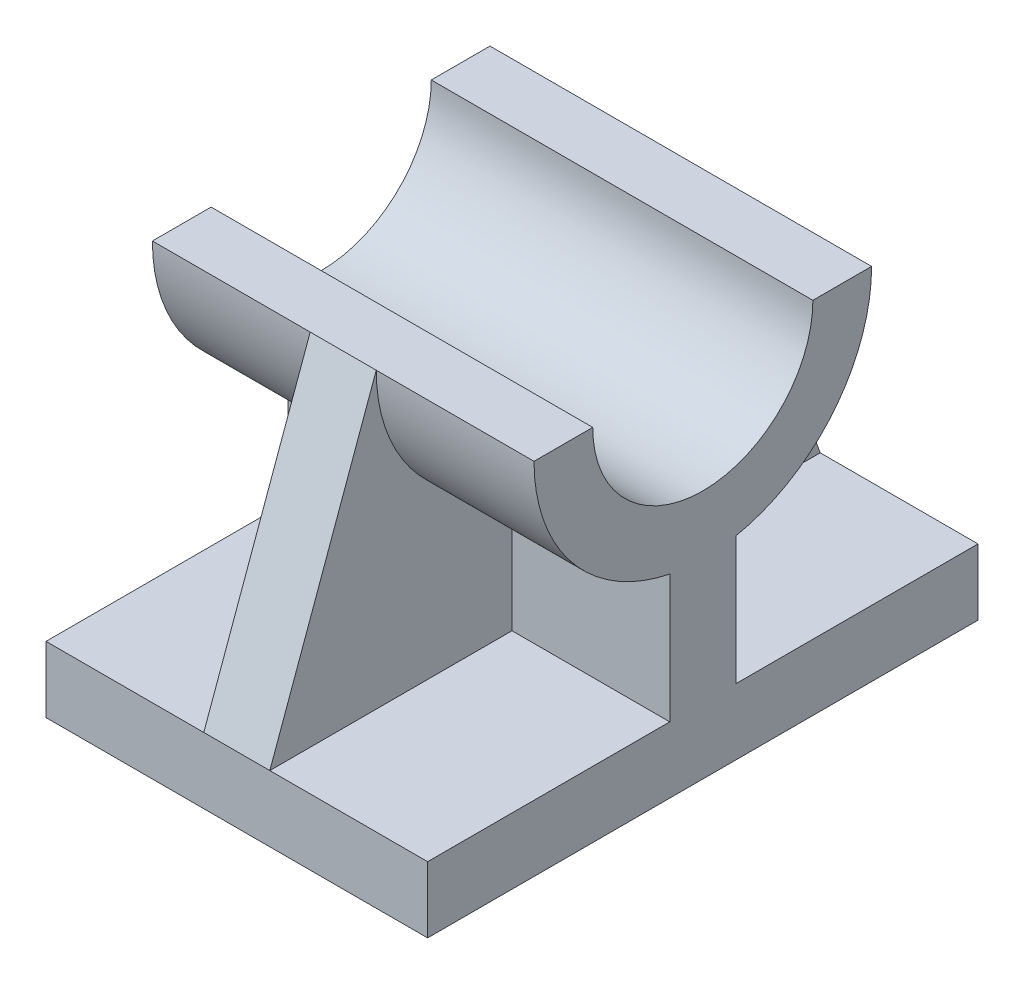
from build123d import *

# Parameters (mm, degrees)
BOSS_EXTRUDE1_DEPTH = 26
RIB9_REACH          = 65.738
SKETCH6_WALL_W      = 172.022520638
SKETCH6_WALL_H      = 9


with BuildPart() as part:
    # Sketch1 → Boss-Extrude1 (new, symmetric)
    with BuildSketch(Plane(origin=(0, 0, 0), x_dir=(0, 0, -1), z_dir=(1, 0, 0))):
        with BuildLine():
            Line((-23, 44.5), (-15, 44.5))
            ThreePointArc((-15, 44.5), (0, 29.5), (15, 44.5))
            Line((15, 44.5), (23, 44.5))
            ThreePointArc((23, 44.5), (17.783419244, 29.914047854), (4.5, 21.944512863))
            Line((4.5, 21.944512863), (4.5, 4.5))
            Line((4.5, 4.5), (37.5, 4.5))
            Line((37.5, 4.5), (37.5, -4.5))
            Line((37.5, -4.5), (-37.5, -4.5))
            Line((-37.5, -4.5), (-37.5, 4.5))
            Line((-37.5, 4.5), (-4.5, 4.5))
            Line((-4.5, 4.5), (-4.5, 21.944512863))
            ThreePointArc((-4.5, 21.944512863), (-17.783419244, 29.914047854), (-23, 44.5))
        make_face()
    extrude(amount=BOSS_EXTRUDE1_DEPTH, both=True)

    # Sketch6 wall → Rib9 (add, up to next)
    with BuildSketch(Plane(origin=(0, 24.5, -30.25), x_dir=(0, -0.940136065162, -0.340799323621), z_dir=(0, 0.340799323621, -0.940136065162)), mode=Mode.PRIVATE) as rib9_sk1:
        Rectangle(SKETCH6_WALL_W, SKETCH6_WALL_H)
    rib9_tool1 = extrude(rib9_sk1.sketch, amount=-RIB9_REACH, mode=Mode.PRIVATE) - part.part
    rib9 = rib9_tool1.solids().sort_by_distance((0, 24.5, -30.25))[0]
    add(rib9)

    # Mirror1: Rib9 across plane
    add(rib9.mirror(Plane.XY))


solid = part.part
